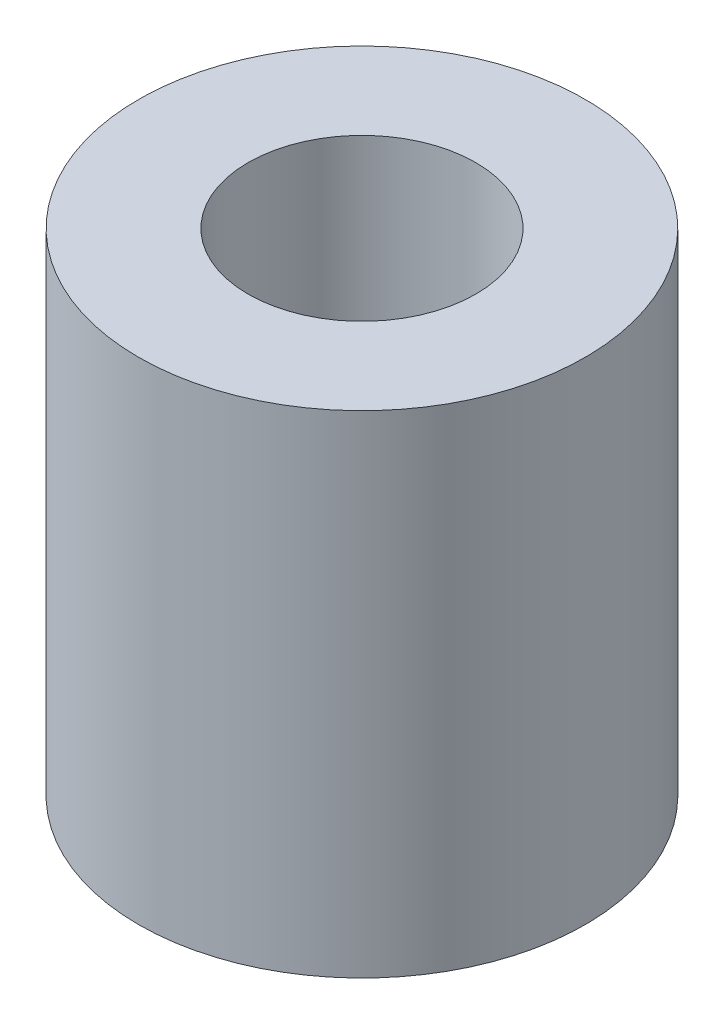
from build123d import *

# Parameters (mm, degrees)
ESQUISSE1_R        = 5
ESQUISSE1_R_2      = 2.55
BOSS_EXTRU_1_DEPTH = 11


with BuildPart() as part:
    # Esquisse1 → Boss.-Extru.1 (new body)
    with BuildSketch(Plane(origin=(0, 0, 0), x_dir=(1, 0, 0), z_dir=(0, 1, 0))):
        Circle(ESQUISSE1_R)
        Circle(ESQUISSE1_R_2, mode=Mode.SUBTRACT)
    extrude(amount=BOSS_EXTRU_1_DEPTH)


solid = part.part
